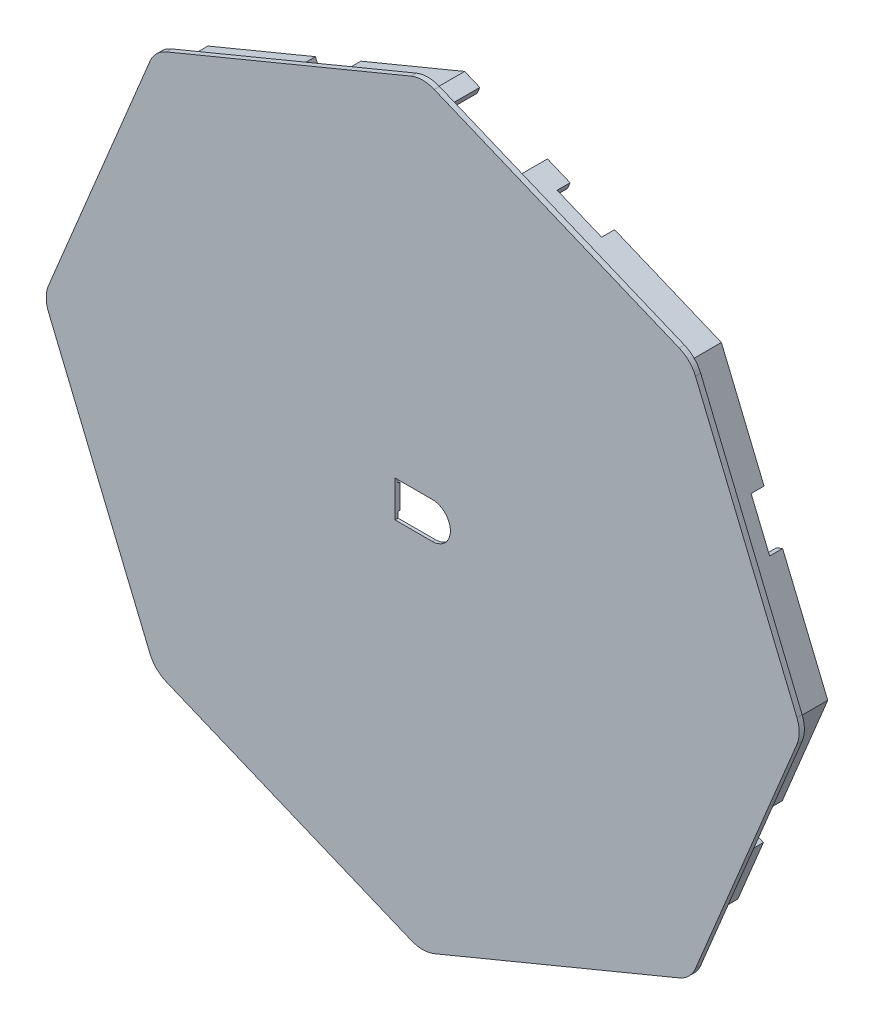
from build123d import *

# Parameters (mm, degrees)
BOSS_EXTRU_1_DEPTH      = 0.6
BOSS_EXTRU_2_DEPTH      = 4.25
ESQUISSE4_W             = 7.2
ESQUISSE4_H             = 5.8
ENL_V_MAT_EXTRU_2_DEPTH = 0.25
ENL_V_MAT_EXTRU_1_DEPTH = 1
ESQUISSE5_W             = 8.472275713
ESQUISSE5_H             = 4.25
ENL_V_MAT_EXTRU_3_DEPTH = 1
ENL_V_MAT_EXTRU_4_DEPTH = 1.5
ESQUISSE8_W             = 4.234206918
ESQUISSE8_H             = 9.1
ENL_V_MAT_EXTRU_5_DEPTH = 5
ESQUISSE10_R            = 37
ESQUISSE10_R_2          = 33.695164562
ESQUISSE10_R_3          = 31.722840226
ENL_V_MAT_EXTRU_6_DEPTH = 0.25


with BuildPart() as part:
    # Esquisse1 → Boss.-Extru.1 (new body)
    with BuildSketch(Plane.XY):
        with BuildLine():
            Line((-19.517262275, 52.622283258), (-47.83583627, 40.892345842))
            ThreePointArc((-47.83583627, 40.892345842), (-48.971317991, 40.133641213), (-49.730022621, 38.998159492))
            Line((-49.730022621, 38.998159492), (-61.459960037, 10.679585497))
            ThreePointArc((-61.459960037, 10.679585497), (-61.726381673, 9.340193484), (-61.459960037, 8.00080147))
            Line((-61.459960037, 8.00080147), (-49.730022621, -20.317772525))
            ThreePointArc((-49.730022621, -20.317772525), (-48.971317991, -21.453254245), (-47.83583627, -22.211958875))
            Line((-47.83583627, -22.211958875), (-19.517262275, -33.941896291))
            ThreePointArc((-19.517262275, -33.941896291), (-18.177870262, -34.208317927), (-16.838478249, -33.941896291))
            Line((-16.838478249, -33.941896291), (11.480095746, -22.211958875))
            ThreePointArc((11.480095746, -22.211958875), (12.615577467, -21.453254245), (13.374282097, -20.317772525))
            Line((13.374282097, -20.317772525), (25.104219513, 8.00080147))
            ThreePointArc((25.104219513, 8.00080147), (25.370641149, 9.340193484), (25.104219513, 10.679585497))
            Line((25.104219513, 10.679585497), (13.374282097, 38.998159492))
            ThreePointArc((13.374282097, 38.998159492), (12.615577467, 40.133641213), (11.480095746, 40.892345842))
            Line((11.480095746, 40.892345842), (-16.838478249, 52.622283258))
            ThreePointArc((-16.838478249, 52.622283258), (-18.177870262, 52.888704894), (-19.517262275, 52.622283258))
        make_face()
    extrude(amount=BOSS_EXTRU_1_DEPTH)

    # Esquisse3 → Boss.-Extru.2 (add)
    with BuildSketch(Plane(origin=(0, 0, 0), x_dir=(-1, 0, 0), z_dir=(0, 0, -1))):
        Polygon((47.874104614, 39.036427835), (18.177870262, 51.337010855), (-11.51836409, 39.036427835), (-23.818947109, 9.340193484), (-11.51836409, -20.356040868), (18.177870262, -32.656623888), (47.874104614, -20.356040868), (60.174687633, 9.340193484), align=None)
        Polygon((47.261811122, 38.424134343), (18.177870262, 50.471097095), (-10.906070598, 38.424134343), (-22.953033349, 9.340193484), (-10.906070598, -19.743747376), (18.177870262, -31.790710127), (47.261811122, -19.743747376), (59.308773873, 9.340193484), align=None, mode=Mode.SUBTRACT)
    extrude(amount=BOSS_EXTRU_2_DEPTH)

    # Esquisse4 → Enlèv. mat.-Extru.2 (cut)
    with BuildSketch(Plane(origin=(0, 0, 0), x_dir=(-1, 0, 0), z_dir=(0, 0, -1))):
        with Locations((17.777870262, 9.340193484)):
            Rectangle(ESQUISSE4_W, ESQUISSE4_H)
    extrude(amount=-ENL_V_MAT_EXTRU_2_DEPTH, mode=Mode.SUBTRACT)

    # Esquisse2 → Enlèv. mat.-Extru.1 (cut)
    with BuildSketch(Plane.XY.offset(0.6)):
        with BuildLine():
            Line((-21.377870262, 11.440193484), (-17.077870262, 11.440193484))
            ThreePointArc((-17.077870262, 11.440193484), (-14.977870262, 9.340193484), (-17.077870262, 7.240193484))
            Line((-17.077870262, 7.240193484), (-21.377870262, 7.240193484))
            Line((-21.377870262, 7.240193484), (-21.377870262, 11.440193484))
        make_face()
    extrude(amount=-ENL_V_MAT_EXTRU_1_DEPTH, mode=Mode.SUBTRACT)

    # Esquisse5 → Enlèv. mat.-Extru.3 (cut)
    with BuildSketch(Plane(origin=(15.488286785, 37.392032013, 0), x_dir=(0.923879533, -0.382683432, 0), z_dir=(0.382683432, 0.923879533, 0))):
        with Locations((-30.305896545, 2.125)):
            Rectangle(ESQUISSE5_W, ESQUISSE5_H)
    extrude(amount=-ENL_V_MAT_EXTRU_3_DEPTH, mode=Mode.SUBTRACT)

    # Esquisse7 → Enlèv. mat.-Extru.4 (cut)
    with BuildSketch(Plane(origin=(0, 0, -4.25), x_dir=(-1, 0, 0), z_dir=(0, 0, -1))):
        Polygon((-17.50496507, 21.47893525), (-15.341384732, 26.654887728), (-16.775432828, 27.254328754), (-18.939013166, 22.078376276), align=None)
        Polygon((-15.640527468, -8.31375739), (-17.820504584, -3.05082707), (-18.55960821, -3.356973816), (-16.379631094, -8.619904136), align=None)
        Polygon((6.698899413, -27.03596472), (6.392752668, -27.775068346), (1.182153756, -25.616767609), (1.488300502, -24.877663983), align=None)
        Polygon((35.048431259, -24.802694958), (29.656841111, -27.03596472), (29.962987856, -27.775068346), (35.354578005, -25.541798584), align=None)
        Polygon((52.17892665, -7.872780379), (52.918030276, -8.178927125), (55.130023531, -2.838703009), (54.390919905, -2.532556263), align=None)
        Polygon((54.32131897, 21.380974752), (55.060422596, 21.687121498), (52.895575827, 26.913523929), (52.156472201, 26.607377183), align=None)
        Polygon((29.879992906, 45.623919187), (30.186139652, 46.363022813), (35.433146758, 44.189641308), (35.127000012, 43.450537682), align=None)
        Polygon((6.286433803, 45.545502837), (5.980287057, 46.284606463), (0.837914202, 44.154565884), (1.144060948, 43.415462258), align=None)
    extrude(amount=-ENL_V_MAT_EXTRU_4_DEPTH, mode=Mode.SUBTRACT)

    # Esquisse8 → Enlèv. mat.-Extru.5 (cut)
    with BuildSketch(Plane(origin=(16.846027311, -16.846027311, 0), x_dir=(0, 0, 1), z_dir=(-0.707106781, 0.707106781, 0))):
        with Locations((-2.332896541, -6.216024436)):
            Rectangle(ESQUISSE8_W, ESQUISSE8_H)
    extrude(amount=ENL_V_MAT_EXTRU_5_DEPTH, mode=Mode.SUBTRACT)

    # Esquisse10 → Enlèv. mat.-Extru.6 (cut)
    with BuildSketch(Plane(origin=(0, 0, 0), x_dir=(-1, 0, 0), z_dir=(0, 0, -1))):
        with Locations((18.177870262, 9.340193484)):
            Circle(ESQUISSE10_R)
        with Locations((18.177870262, 9.340193484)):
            Circle(ESQUISSE10_R_2, mode=Mode.SUBTRACT)
        with Locations((18.177870262, 9.340193484)):
            Circle(ESQUISSE10_R_3)
        with BuildLine():
            ThreePointArc((8.629474483, -19.000883079), (7.954258202, -18.158024157), (8.438947192, -17.192931016))
            Line((8.438947192, -17.192931016), (17.986552226, -11.535066045))
            ThreePointArc((17.986552226, -11.535066045), (18.82848928, -11.452124028), (19.43270633, -12.044288816))
            Line((19.43270633, -12.044288816), (22.064659101, -19.064098879))
            ThreePointArc((22.064659101, -19.064098879), (21.978252148, -19.942041149), (21.230378007, -20.409943981))
            ThreePointArc((21.230378007, -20.409943981), (14.854392641, -20.380892957), (8.629474483, -19.000883079))
        make_face(mode=Mode.SUBTRACT)
        with BuildLine():
            ThreePointArc((-9.028864593, -3.076813453), (-9.009983812, -2.207321044), (-8.317286979, -1.681445935))
            Line((-8.317286979, -1.681445935), (-1.19815408, -0.242222171))
            ThreePointArc((-1.19815408, -0.242222171), (-0.366815224, -0.448392382), (0, -1.222393054))
            Line((0, -1.222393054), (0, -12.288147137))
            ThreePointArc((0, -12.288147137), (-0.589785937, -13.200136403), (-1.663448846, -13.036368781))
            ThreePointArc((-1.663448846, -13.036368781), (-5.86746257, -8.442113783), (-9.028864593, -3.076813453))
        make_face(mode=Mode.SUBTRACT)
        with BuildLine():
            ThreePointArc((45.067106946, 6.138146709), (44.894934964, 5.789771119), (44.602964507, 5.533330102))
            Line((44.602964507, 5.533330102), (7.788041987, -15.798453932))
            ThreePointArc((7.788041987, -15.798453932), (7.503184877, -15.909493906), (7.198091336, -15.929277251))
            ThreePointArc((7.198091336, -15.929277251), (6.076699774, -15.338467897), (5.709966854, -14.12517416))
            ThreePointArc((5.709966854, -14.12517416), (5.75211903, -13.9233695), (5.834757849, -13.734497183))
            Line((5.834757849, -13.734497183), (11.368351796, -3.972898843))
            ThreePointArc((11.368351796, -3.972898843), (11.526990503, -3.763165497), (11.734819104, -3.602039494))
            Line((11.734819104, -3.602039494), (32.356885138, 8.41491488))
            ThreePointArc((32.356885138, 8.41491488), (32.611794991, 8.519521111), (32.885576478, 8.550588678))
            Line((32.885576478, 8.550588678), (43.877622029, 8.27334987))
            ThreePointArc((43.877622029, 8.27334987), (44.231525818, 8.199016312), (44.535851129, 8.00367181))
            ThreePointArc((44.535851129, 8.00367181), (45.060078773, 7.144552125), (45.067106946, 6.138146709))
        make_face(mode=Mode.SUBTRACT)
        with BuildLine():
            Line((24.175060065, -8.128386738), (30.01381974, -4.787836408))
            ThreePointArc((30.01381974, -4.787836408), (30.724883525, -4.679083859), (31.324975502, -5.075730354))
            Line((31.324975502, -5.075730354), (36.839227631, -12.81883915))
            ThreePointArc((36.839227631, -12.81883915), (37.014427283, -13.54169903), (36.642073221, -14.185573067))
            ThreePointArc((36.642073221, -14.185573067), (33.009952923, -16.628976827), (29.060051166, -18.515983955))
            ThreePointArc((29.060051166, -18.515983955), (28.325186439, -18.513173549), (27.790668521, -18.008867431))
            Line((27.790668521, -18.008867431), (23.766153097, -9.420697227))
            ThreePointArc((23.766153097, -9.420697227), (23.718249078, -8.694692177), (24.175060065, -8.128386738))
        make_face(mode=Mode.SUBTRACT)
        with BuildLine():
            ThreePointArc((36.372243136, -2.617503272), (36.152619714, -1.788215293), (36.656468623, -1.093888803))
            Line((36.656468623, -1.093888803), (45.920334541, 3.963791824))
            ThreePointArc((45.920334541, 3.963791824), (47.000383562, 3.885438986), (47.375841246, 2.869724172))
            ThreePointArc((47.375841246, 2.869724172), (45.508486043, -2.801714264), (42.551674298, -7.989150403))
            ThreePointArc((42.551674298, -7.989150403), (41.778731513, -8.408811326), (40.973251339, -8.055601009))
            Line((40.973251339, -8.055601009), (36.372243136, -2.617503272))
        make_face(mode=Mode.SUBTRACT)
        with BuildLine():
            Line((-0.929844819, 4.969893114), (-10.375011226, 4.305629072))
            ThreePointArc((-10.375011226, 4.305629072), (-11.074140767, 4.525739118), (-11.435366068, 5.163506183))
            ThreePointArc((-11.435366068, 5.163506183), (-11.728458211, 9.340193484), (-11.435366068, 13.516880784))
            ThreePointArc((-11.435366068, 13.516880784), (-11.074140767, 14.154647849), (-10.375011226, 14.374757895))
            Line((-10.375011226, 14.374757895), (-0.929844819, 13.710493854))
            ThreePointArc((-0.929844819, 13.710493854), (-0.26851002, 13.394809954), (0, 12.712957764))
            Line((0, 12.712957764), (0, 9.340193484))
            Line((0, 9.340193484), (0, 5.967429204))
            ThreePointArc((0, 5.967429204), (-0.26851002, 5.285577013), (-0.929844819, 4.969893114))
        make_face(mode=Mode.SUBTRACT)
        with BuildLine():
            Line((0, 30.968534104), (0, 19.902780021))
            ThreePointArc((0, 19.902780021), (-0.366815224, 19.12877935), (-1.19815408, 18.922609138))
            Line((-1.19815408, 18.922609138), (-8.317286979, 20.361832902))
            ThreePointArc((-8.317286979, 20.361832902), (-9.009983812, 20.887708011), (-9.028864593, 21.75720042))
            ThreePointArc((-9.028864593, 21.75720042), (-5.86746257, 27.12250075), (-1.663448846, 31.716755748))
            ThreePointArc((-1.663448846, 31.716755748), (-0.589785937, 31.880523371), (0, 30.968534104))
        make_face(mode=Mode.SUBTRACT)
        with BuildLine():
            Line((1.627352957, -11.107626243), (1.627352957, 9.340193484))
            Line((1.627352957, 9.340193484), (1.627352957, 29.78801321))
            ThreePointArc((1.627352957, 29.78801321), (1.716726077, 30.20124279), (1.968870328, 30.540609136))
            Line((1.968870328, 30.540609136), (2.410591458, 30.927092348))
            ThreePointArc((2.410591458, 30.927092348), (3.190943909, 31.167042515), (3.890066952, 30.745434873))
            Line((3.890066952, 30.745434873), (10.027346972, 21.920204943))
            ThreePointArc((10.027346972, 21.920204943), (10.160553474, 21.64843796), (10.206354106, 21.349266492))
            Line((10.206354106, 21.349266492), (10.206354106, -2.668879525))
            ThreePointArc((10.206354106, -2.668879525), (10.160553474, -2.968050993), (10.027346972, -3.239817976))
            Line((10.027346972, -3.239817976), (3.890066952, -12.065047906))
            ThreePointArc((3.890066952, -12.065047906), (3.190943909, -12.486655548), (2.410591458, -12.24670538))
            Line((2.410591458, -12.24670538), (1.968870328, -11.860222169))
            ThreePointArc((1.968870328, -11.860222169), (1.716726077, -11.520855823), (1.627352957, -11.107626243))
        make_face(mode=Mode.SUBTRACT)
        with BuildLine():
            Line((22.064659101, 37.744485846), (19.43270633, 30.724675784))
            ThreePointArc((19.43270633, 30.724675784), (18.82848928, 30.132510995), (17.986552226, 30.215453012))
            Line((17.986552226, 30.215453012), (8.438947192, 35.873317984))
            ThreePointArc((8.438947192, 35.873317984), (7.954258202, 36.838411125), (8.629474483, 37.681270047))
            ThreePointArc((8.629474483, 37.681270047), (14.854392641, 39.061279924), (21.230378007, 39.090330949))
            ThreePointArc((21.230378007, 39.090330949), (21.978252148, 38.622428116), (22.064659101, 37.744485846))
        make_face(mode=Mode.SUBTRACT)
        with BuildLine():
            Line((14.177870262, 12.240193484), (15.173703377, 12.240193484))
            ThreePointArc((15.173703377, 12.240193484), (14.539475748, 15.575163017), (17.126621067, 13.377221805))
            Line((17.126621067, 13.377221805), (18.976236491, 12.240193484))
            Line((18.976236491, 12.240193484), (21.377870262, 12.240193484))
            Line((21.377870262, 12.240193484), (21.377870262, 10.763818676))
            Line((21.377870262, 10.763818676), (21.945839013, 10.414666875))
            ThreePointArc((21.945839013, 10.414666875), (23.943358867, 11.028360494), (25.174942226, 9.340193484))
            ThreePointArc((25.174942226, 9.340193484), (23.943358867, 7.652026473), (21.945839013, 8.265720092))
            Line((21.945839013, 8.265720092), (21.377870262, 7.916568292))
            Line((21.377870262, 7.916568292), (21.377870262, 6.440193484))
            Line((21.377870262, 6.440193484), (18.976236491, 6.440193484))
            Line((18.976236491, 6.440193484), (17.126621067, 5.303165162))
            ThreePointArc((17.126621067, 5.303165162), (14.539475748, 3.10522395), (15.173703377, 6.440193484))
            Line((15.173703377, 6.440193484), (14.177870262, 6.440193484))
            Line((14.177870262, 6.440193484), (14.177870262, 12.240193484))
        make_face(mode=Mode.SUBTRACT)
        with BuildLine():
            ThreePointArc((11.734819104, 22.282426461), (11.526990503, 22.443552464), (11.368351796, 22.65328581))
            Line((11.368351796, 22.65328581), (5.834757849, 32.41488415))
            ThreePointArc((5.834757849, 32.41488415), (5.75211903, 32.603756468), (5.709966854, 32.805561128))
            ThreePointArc((5.709966854, 32.805561128), (6.076699774, 34.018854865), (7.198091336, 34.609664218))
            ThreePointArc((7.198091336, 34.609664218), (7.503184877, 34.589880874), (7.788041987, 34.478840899))
            Line((7.788041987, 34.478840899), (44.602964507, 13.147056865))
            ThreePointArc((44.602964507, 13.147056865), (44.894934964, 12.890615848), (45.067106946, 12.542240258))
            ThreePointArc((45.067106946, 12.542240258), (45.060078773, 11.535834842), (44.535851129, 10.676715158))
            ThreePointArc((44.535851129, 10.676715158), (44.231525818, 10.481370655), (43.877622029, 10.407037098))
            Line((43.877622029, 10.407037098), (32.885576478, 10.129798289))
            ThreePointArc((32.885576478, 10.129798289), (32.611794991, 10.160865857), (32.356885138, 10.265472088))
            Line((32.356885138, 10.265472088), (11.734819104, 22.282426461))
        make_face(mode=Mode.SUBTRACT)
        with BuildLine():
            Line((36.839227631, 31.499226117), (31.324975502, 23.756117322))
            ThreePointArc((31.324975502, 23.756117322), (30.724883525, 23.359470827), (30.01381974, 23.468223375))
            Line((30.01381974, 23.468223375), (24.175060065, 26.808773705))
            ThreePointArc((24.175060065, 26.808773705), (23.718249078, 27.375079144), (23.766153097, 28.101084194))
            Line((23.766153097, 28.101084194), (27.790668521, 36.689254399))
            ThreePointArc((27.790668521, 36.689254399), (28.325186439, 37.193560516), (29.060051166, 37.196370922))
            ThreePointArc((29.060051166, 37.196370922), (33.009952923, 35.309363795), (36.642073221, 32.865960035))
            ThreePointArc((36.642073221, 32.865960035), (37.014427283, 32.222085997), (36.839227631, 31.499226117))
        make_face(mode=Mode.SUBTRACT)
        with BuildLine():
            ThreePointArc((36.656468623, 19.77427577), (36.152619714, 20.468602261), (36.372243136, 21.29789024))
            Line((36.372243136, 21.29789024), (40.973251339, 26.735987977))
            ThreePointArc((40.973251339, 26.735987977), (41.778731513, 27.089198294), (42.551674298, 26.66953737))
            ThreePointArc((42.551674298, 26.66953737), (45.508486043, 21.482101231), (47.375841246, 15.810662795))
            ThreePointArc((47.375841246, 15.810662795), (47.000383562, 14.794947981), (45.920334541, 14.716595144))
            Line((45.920334541, 14.716595144), (36.656468623, 19.77427577))
        make_face(mode=Mode.SUBTRACT)
    extrude(amount=-ENL_V_MAT_EXTRU_6_DEPTH, mode=Mode.SUBTRACT)


solid = part.part
